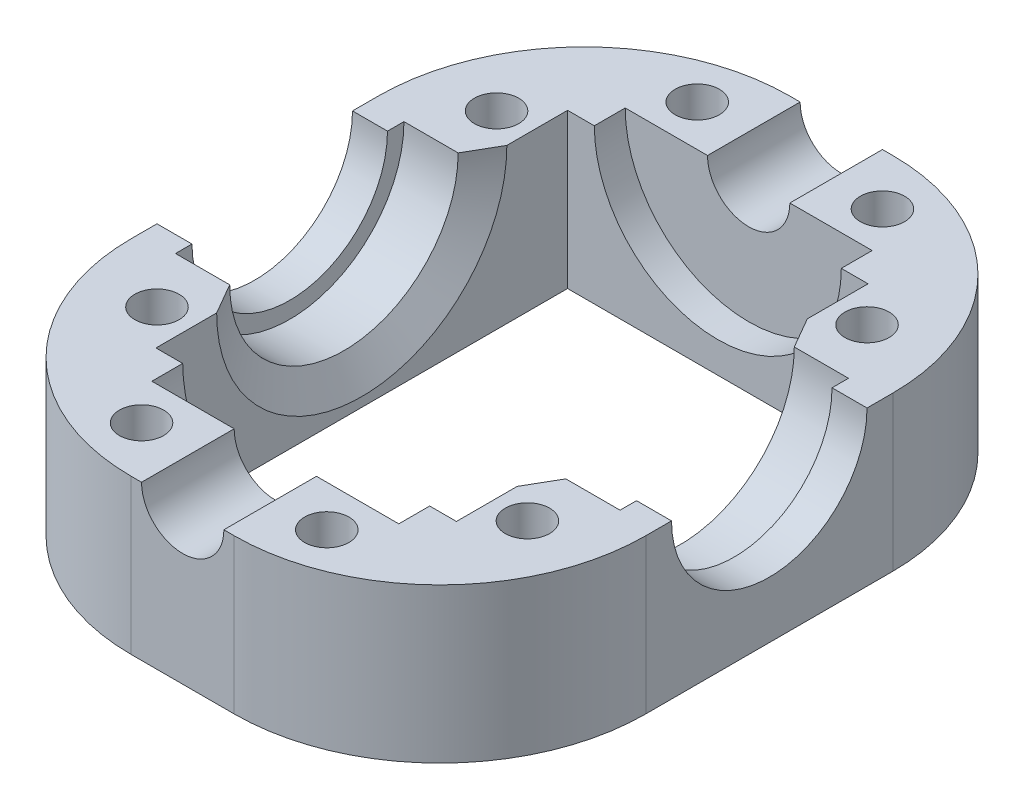
from build123d import *

# Parameters (mm, degrees)
SKETCH1_W             = 50
SKETCH1_H             = 64
SKETCH1_W_2           = 29.2
SKETCH1_H_2           = 40
BOSS_EXTRUDE1_DEPTH   = 15
SKETCH3_W             = 7
SKETCH3_H             = 11.1
SKETCH4_R             = 9.5
CUT_EXTRUDE2_DEPTH    = 51
SKETCH5_R             = 4
CUT_EXTRUDE3_DEPTH    = 65
SKETCH8_R             = 2.15
CUT_EXTRUDE6_DEPTH    = 16
FILLET1_R             = 20
CHAMFER1_SIZE         = 3
CHAMFER1_SIZE2        = 1.732050808
CHAMFER1_PART_2_SIZE  = 3
CHAMFER1_PART_2_SIZE2 = 1.732050808
SKETCH9_W             = 12
SKETCH9_H             = 3


with BuildPart() as part:
    # Sketch1 → Boss-Extrude1 (new body)
    with BuildSketch(Plane(origin=(0, 0, 0), x_dir=(1, 0, 0), z_dir=(0, 1, 0))):
        Rectangle(SKETCH1_W, SKETCH1_H)
        Rectangle(SKETCH1_W_2, SKETCH1_H_2, mode=Mode.SUBTRACT)
    extrude(amount=BOSS_EXTRUDE1_DEPTH)

    # Sketch3 → Cut-Revolve1 (revolve, cut)
    with BuildSketch(Plane(origin=(0, 15, 0), x_dir=(1, 0, 0), z_dir=(0, 1, 0))):
        with Locations((18.1, -5.55)):
            Rectangle(SKETCH3_W, SKETCH3_H)
        with Locations((-18.1, -5.55)):
            Rectangle(SKETCH3_W, SKETCH3_H)
    revolve(axis=Axis((14.6, 15, 0), (1, 0, 0)), mode=Mode.SUBTRACT)

    # Sketch4 → Cut-Extrude2 (cut, through all)
    with BuildSketch(Plane(origin=(25, 0, 0), x_dir=(0, 0, -1), z_dir=(1, 0, 0))):
        with Locations((0, 15)):
            Circle(SKETCH4_R)
    extrude(amount=-CUT_EXTRUDE2_DEPTH, mode=Mode.SUBTRACT)

    # Sketch5 → Cut-Extrude3 (cut, through all)
    with BuildSketch(Plane.XY.offset(32)):
        with Locations((0, 15)):
            Circle(SKETCH5_R)
    extrude(amount=-CUT_EXTRUDE3_DEPTH, mode=Mode.SUBTRACT)

    # Sketch8 → Cut-Extrude6 (cut, through all)
    with BuildSketch(Plane(origin=(0, 15, 0), x_dir=(1, 0, 0), z_dir=(0, 1, 0))):
        with Locations(Location((18, 16.5, 0), (0, 0, 270))):  # turned: the seam where the file's is
            Circle(SKETCH8_R)
        with Locations(Location((18, -16.5, 0), (0, 0, 270))):  # turned: the seam where the file's is
            Circle(SKETCH8_R)
        with Locations(Location((-18, -16.5, 0), (0, 0, 270))):  # turned: the seam where the file's is
            Circle(SKETCH8_R)
        with Locations(Location((-18, 16.5, 0), (0, 0, 270))):  # turned: the seam where the file's is
            Circle(SKETCH8_R)
        with Locations(Location((9, -27, 0), (0, 0, 270))):  # turned: the seam where the file's is
            Circle(SKETCH8_R)
        with Locations(Location((-9, -27, 0), (0, 0, 270))):  # turned: the seam where the file's is
            Circle(SKETCH8_R)
        with Locations(Location((-9, 27, 0), (0, 0, 270))):  # turned: the seam where the file's is
            Circle(SKETCH8_R)
        with Locations(Location((9, 27, 0), (0, 0, 270))):  # turned: the seam where the file's is
            Circle(SKETCH8_R)
    extrude(amount=-CUT_EXTRUDE6_DEPTH, mode=Mode.SUBTRACT)

    # Fillet1
    fillet1_edges = [part.edges().sort_by_distance(p)[0] for p in [
        (-25, 7.5, -32),
        (25, 7.5, -32),
        (25, 7.5, 32),
        (-25, 7.5, 32),
    ]]
    fillet(fillet1_edges, radius=FILLET1_R)

    # Chamfer1
    chamfer1_edges = [part.edges().sort_by_distance(p)[0] for p in [
        (14.6, 3.9, 0),
    ]]
    chamfer1_side = [part.faces().sort_by_distance(p)[0] for p in [
        (14.6, 0.427200187, 0),
    ]]
    chamfer(chamfer1_edges, length=CHAMFER1_SIZE, length2=CHAMFER1_SIZE2, reference=chamfer1_side[0])

    # Chamfer1 part 2
    chamfer1_part_2_edges = [part.edges().sort_by_distance(p)[0] for p in [
        (-14.6, 3.9, 0),
    ]]
    chamfer1_part_2_side = [part.faces().sort_by_distance(p)[0] for p in [
        (-14.6, 0.427200187, 0),
    ]]
    chamfer(chamfer1_part_2_edges, length=CHAMFER1_PART_2_SIZE, length2=CHAMFER1_PART_2_SIZE2, reference=chamfer1_part_2_side[0])

    # Sketch9 → Cut-Revolve2 (revolve, cut)
    with BuildSketch(Plane(origin=(0, 15, 0), x_dir=(1, 0, 0), z_dir=(0, 1, 0))):
        with Locations((-6, -21.5)):
            Rectangle(SKETCH9_W, SKETCH9_H)
        with Locations((-6, 21.5)):
            Rectangle(SKETCH9_W, SKETCH9_H)
    revolve(axis=Axis((0, 15, -29.871415895), (0, 0, 1)), mode=Mode.SUBTRACT)


solid = part.part
